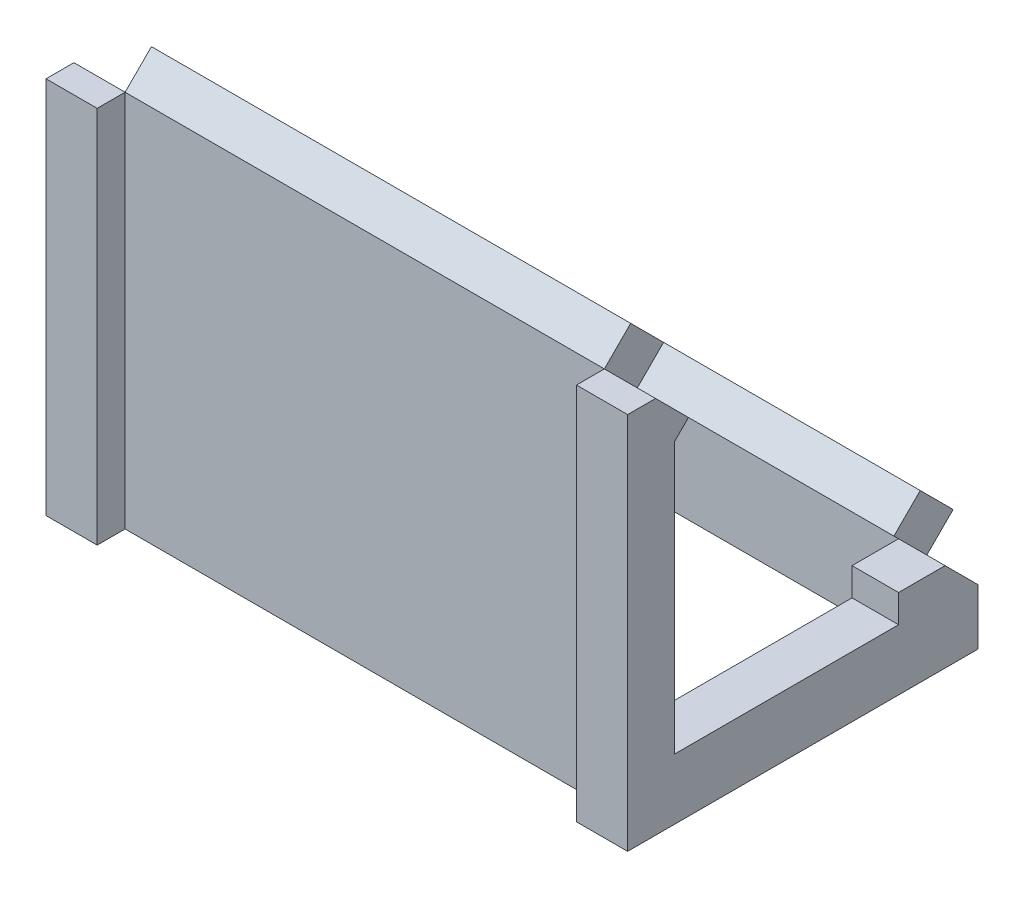
from build123d import *

# Parameters (mm, degrees)
BOSS_EXTRUDE3_DEPTH  = 125
SKETCH3_W            = 125
SKETCH3_H            = 69.296464556
BOSS_EXTRUDE5_DEPTH  = 12
CUT_EXTRUDE1_DEPTH   = 159.836393815
SKETCH7_W            = 105
SKETCH7_H            = 10
BOSS_EXTRUDE6_DEPTH  = 8
SKETCH8_W            = 105
SKETCH8_H            = 10
BOSS_EXTRUDE7_DEPTH  = 8
SKETCH9_W            = 105
SKETCH9_H            = 55.154328932
CUT_EXTRUDE2_DEPTH   = 161.78246173
SKETCH11_W           = 10
SKETCH11_H           = 55.154328932
CUT_EXTRUDE3_DEPTH   = 6
SKETCH12_W           = 10
SKETCH12_H           = 55.154328932
CUT_EXTRUDE4_DEPTH   = 6
SKETCH13_W           = 105
SKETCH13_H           = 61.154328932
CUT_EXTRUDE6_DEPTH   = 3
SKETCH14_R           = 1.9
CUT_EXTRUDE8_DEPTH   = 6
SKETCH15_R           = 1.9
CUT_EXTRUDE9_DEPTH   = 6
BOSS_EXTRUDE9_REACH  = 158.4
SKETCH25_W           = 10
SKETCH25_H           = 6
BOSS_EXTRUDE13_DEPTH = 10
CUT_EXTRUDE10_DEPTH  = 1
CUT_EXTRUDE11_DEPTH  = 1
SKETCH29_W           = 11
SKETCH29_H           = 81.296464556
BOSS_EXTRUDE15_DEPTH = 6
SKETCH31_R           = 2
CUT_EXTRUDE16_DEPTH  = 6
SKETCH32_R           = 2
CUT_EXTRUDE17_DEPTH  = 6
CUT_EXTRUDE22_DEPTH  = 157.400127877
CUT_EXTRUDE23_DEPTH  = 157.400127877


with BuildPart() as part:
    # Sketch1 → Boss-Extrude3 (new body)
    with BuildSketch(Plane(origin=(0, 0, 0), x_dir=(0, 0, -1), z_dir=(1, 0, 0))):
        Polygon((0, 0), (69.296464556, 0), (0, 69.296464556), align=None)
    extrude(amount=-BOSS_EXTRUDE3_DEPTH)

    # Sketch3 → Boss-Extrude5 (add)
    with BuildSketch(Plane.XZ):
        with Locations((-62.5, -34.648232278)):
            Rectangle(SKETCH3_W, SKETCH3_H)
    extrude(amount=BOSS_EXTRUDE5_DEPTH)

    # Sketch6 → Cut-Extrude1 (cut, through all)
    with BuildSketch(Plane.ZY.offset(125)):
        Polygon((-7.071067812, 62.225396744), (-62.225396744, 7.071067812), (-7.071067812, 7.071067812), align=None)
    extrude(amount=-CUT_EXTRUDE1_DEPTH, mode=Mode.SUBTRACT)

    # Sketch7 → Boss-Extrude6 (add)
    with BuildSketch(Plane(origin=(0, 34.648232278, -34.648232278), x_dir=(1, 0, 0), z_dir=(0, 0.7071067811865515, -0.7071067811865436))):
        with Locations((-62.5, 44)):
            Rectangle(SKETCH7_W, SKETCH7_H)
    extrude(amount=BOSS_EXTRUDE6_DEPTH)

    # Sketch8 → Boss-Extrude7 (add)
    with BuildSketch(Plane(origin=(0, 34.648232278, -34.648232278), x_dir=(1, 0, 0), z_dir=(0, 0.7071067811865515, -0.7071067811865436))):
        with Locations((-62.5, -44)):
            Rectangle(SKETCH8_W, SKETCH8_H)
    extrude(amount=BOSS_EXTRUDE7_DEPTH)

    # Sketch9 → Cut-Extrude2 (cut, through all)
    with BuildSketch(Plane(origin=(0, 7.071067812, 0), x_dir=(1, 0, 0), z_dir=(0, 1, 0))):
        with Locations((-62.5, 34.648232278)):
            Rectangle(SKETCH9_W, SKETCH9_H)
    extrude(amount=-CUT_EXTRUDE2_DEPTH, mode=Mode.SUBTRACT)

    # Sketch11 → Cut-Extrude3 (cut)
    with BuildSketch(Plane(origin=(0, 7.071067812, 0), x_dir=(1, 0, 0), z_dir=(0, 1, 0))):
        with Locations((-5, 34.648232278)):
            Rectangle(SKETCH11_W, SKETCH11_H)
    extrude(amount=-CUT_EXTRUDE3_DEPTH, mode=Mode.SUBTRACT)

    # Sketch12 → Cut-Extrude4 (cut)
    with BuildSketch(Plane(origin=(0, 7.071067812, 0), x_dir=(1, 0, 0), z_dir=(0, 1, 0))):
        with Locations((-120, 34.648232278)):
            Rectangle(SKETCH12_W, SKETCH12_H)
    extrude(amount=-CUT_EXTRUDE4_DEPTH, mode=Mode.SUBTRACT)

    # Sketch13 → Cut-Extrude6 (cut)
    with BuildSketch(Plane(origin=(0, 0, -7.071067812), x_dir=(-1, 0, 0), z_dir=(0, 0, -1))):
        with Locations((62.5, 31.648232278)):
            Rectangle(SKETCH13_W, SKETCH13_H)
    extrude(amount=-CUT_EXTRUDE6_DEPTH, mode=Mode.SUBTRACT)

    # Sketch14 → Cut-Extrude8 (cut)
    with BuildSketch(Plane(origin=(0, 34.648232278, -34.648232278), x_dir=(1, 0, 0), z_dir=(0, 0.7071067811865515, -0.7071067811865436))):
        with Locations(Location((-6.25, 42.75, 0), (0, 0, 270))):
            Circle(SKETCH14_R)
    cut_extrude8 = extrude(amount=-CUT_EXTRUDE8_DEPTH, mode=Mode.SUBTRACT)

    # Mirror1: Cut-Extrude8 across plane
    add(cut_extrude8.mirror(Plane(origin=(-62.5, 0, 0), x_dir=(0, 0, 1), z_dir=(1, 0, 0))), mode=Mode.SUBTRACT)

    # Sketch15 → Cut-Extrude9 (cut)
    with BuildSketch(Plane(origin=(0, 34.648232278, -34.648232278), x_dir=(1, 0, 0), z_dir=(0, 0.7071067811865515, -0.7071067811865436))):
        with Locations(Location((-6.25, -42.75, 0), (0, 0, 270))):
            Circle(SKETCH15_R)
    cut_extrude9 = extrude(amount=-CUT_EXTRUDE9_DEPTH, mode=Mode.SUBTRACT)

    # Mirror2: Cut-Extrude9 across plane
    add(cut_extrude9.mirror(Plane(origin=(-62.5, 0, 0), x_dir=(0, 0, 1), z_dir=(1, 0, 0))), mode=Mode.SUBTRACT)

    # Sketch22 → Boss-Extrude9 (add, up to next)
    with BuildSketch(Plane.ZY.offset(10), mode=Mode.PRIVATE) as boss_extrude9_sk1:
        Polygon((-7.071067812, 62.225396744), (-4.071067812, 59.225396744), (-4.071067812, 62.225396744), align=None)
    boss_extrude9_tool1 = extrude(boss_extrude9_sk1.sketch, amount=BOSS_EXTRUDE9_REACH, mode=Mode.PRIVATE) - part.part
    add(boss_extrude9_tool1.solids().sort_by_distance((-10, 61.225397, -5.071068))[0])

    # Sketch25 → Boss-Extrude13 (add)
    with BuildSketch(Plane.XY.offset(-62.225396744)):
        with Locations((-5, 4.071067812)):
            Rectangle(SKETCH25_W, SKETCH25_H)
        with Locations((-120, 4.071067812)):
            Rectangle(SKETCH25_W, SKETCH25_H)
    extrude(amount=BOSS_EXTRUDE13_DEPTH)

    # Sketch26 → Cut-Extrude10 (cut)
    with BuildSketch(Plane(origin=(-10, 0, 0), x_dir=(0, 0, -1), z_dir=(1, 0, 0))):
        Polygon((0, 69.296464556), (7.071067812, 62.225396744), (12.727922061, 67.882250994), (5.656854249, 74.953318806), align=None)
    cut_extrude10 = extrude(amount=-CUT_EXTRUDE10_DEPTH, mode=Mode.SUBTRACT)

    # Sketch27 → Cut-Extrude11 (cut)
    with BuildSketch(Plane(origin=(-10, 0, 0), x_dir=(0, 0, -1), z_dir=(1, 0, 0))):
        Polygon((62.225396744, 7.071067812), (69.296464556, 0), (74.953318806, 5.656854249), (67.882250994, 12.727922061), align=None)
    cut_extrude11 = extrude(amount=-CUT_EXTRUDE11_DEPTH, mode=Mode.SUBTRACT)

    # Mirror3: Cut-Extrude10, Cut-Extrude11 across plane
    add(cut_extrude10.mirror(Plane(origin=(-62.5, 0, 0), x_dir=(0, 0, 1), z_dir=(1, 0, 0))), mode=Mode.SUBTRACT)
    add(cut_extrude11.mirror(Plane(origin=(-62.5, 0, 0), x_dir=(0, 0, 1), z_dir=(1, 0, 0))), mode=Mode.SUBTRACT)

    # Sketch29 → Boss-Extrude15 (add)
    with BuildSketch(Plane.XY):
        with Locations((-5.5, 28.648232278)):
            Rectangle(SKETCH29_W, SKETCH29_H)
    boss_extrude15 = extrude(amount=BOSS_EXTRUDE15_DEPTH)

    # Mirror4: Boss-Extrude15 across plane
    add(boss_extrude15.mirror(Plane(origin=(-62.5, 0, 0), x_dir=(0, 0, 1), z_dir=(1, 0, 0))))

    # Sketch31 → Cut-Extrude16 (cut)
    with BuildSketch(Plane(origin=(0, 34.648232278, -34.648232278), x_dir=(1, 0, 0), z_dir=(0, 0.7071067811865513, -0.7071067811865438))):
        with Locations(Location((-6.25, 42.75, 0), (0, 0, 270))):
            Circle(SKETCH31_R)
    cut_extrude16 = extrude(amount=-CUT_EXTRUDE16_DEPTH, mode=Mode.SUBTRACT)

    # Sketch32 → Cut-Extrude17 (cut)
    with BuildSketch(Plane(origin=(0, 34.648232278, -34.648232278), x_dir=(1, 0, 0), z_dir=(0, 0.7071067811865513, -0.7071067811865438))):
        with Locations(Location((-6.25, -42.75, 0), (0, 0, 270))):
            Circle(SKETCH32_R)
    cut_extrude17 = extrude(amount=-CUT_EXTRUDE17_DEPTH, mode=Mode.SUBTRACT)

    # Mirror5: Cut-Extrude16, Cut-Extrude17 across plane
    add(cut_extrude16.mirror(Plane(origin=(-62.5, 0, 0), x_dir=(0, 0, 1), z_dir=(1, 0, 0))), mode=Mode.SUBTRACT)
    add(cut_extrude17.mirror(Plane(origin=(-62.5, 0, 0), x_dir=(0, 0, 1), z_dir=(1, 0, 0))), mode=Mode.SUBTRACT)

    # Sketch41 → Cut-Extrude22 (cut, through all)
    with BuildSketch(Plane.ZY.offset(10)):
        Polygon((-7.071067812, 1.071067812), (-4.071067812, 1.071067812), (-4.071067812, 59.225396744), (-7.071067812, 62.225396744), align=None)
    extrude(amount=-CUT_EXTRUDE22_DEPTH, mode=Mode.SUBTRACT)

    # Sketch42 → Cut-Extrude23 (cut, through all)
    with BuildSketch(Plane(origin=(-115, 0, 0), x_dir=(0, 0, -1), z_dir=(1, 0, 0))):
        Polygon((7.071067812, 1.071067812), (4.071067812, 1.071067812), (4.071067812, 59.225396744), (7.071067812, 62.225396744), align=None)
    extrude(amount=-CUT_EXTRUDE23_DEPTH, mode=Mode.SUBTRACT)


solid = part.part
